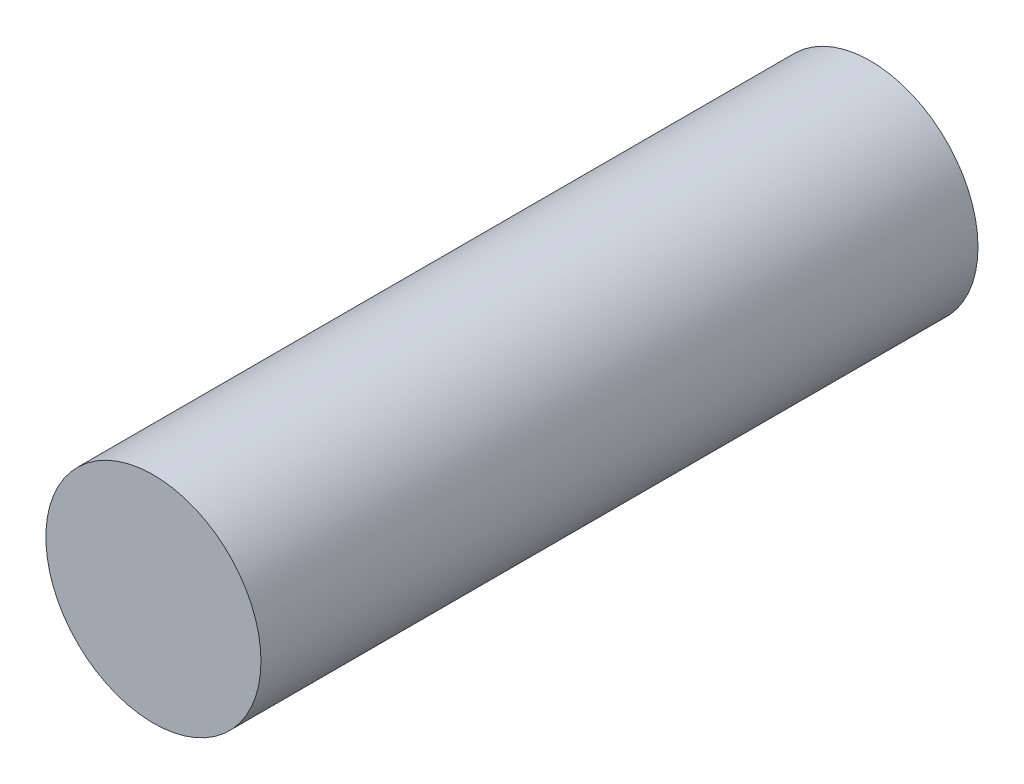
from build123d import *

# Parameters (mm, degrees)
ESQUISSE1_R        = 3
BOSS_EXTRU_1_DEPTH = 20


with BuildPart() as part:
    # Esquisse1 → Boss.-Extru.1 (new body)
    with BuildSketch(Plane.XY):
        Circle(ESQUISSE1_R)
    extrude(amount=BOSS_EXTRU_1_DEPTH)


solid = part.part
